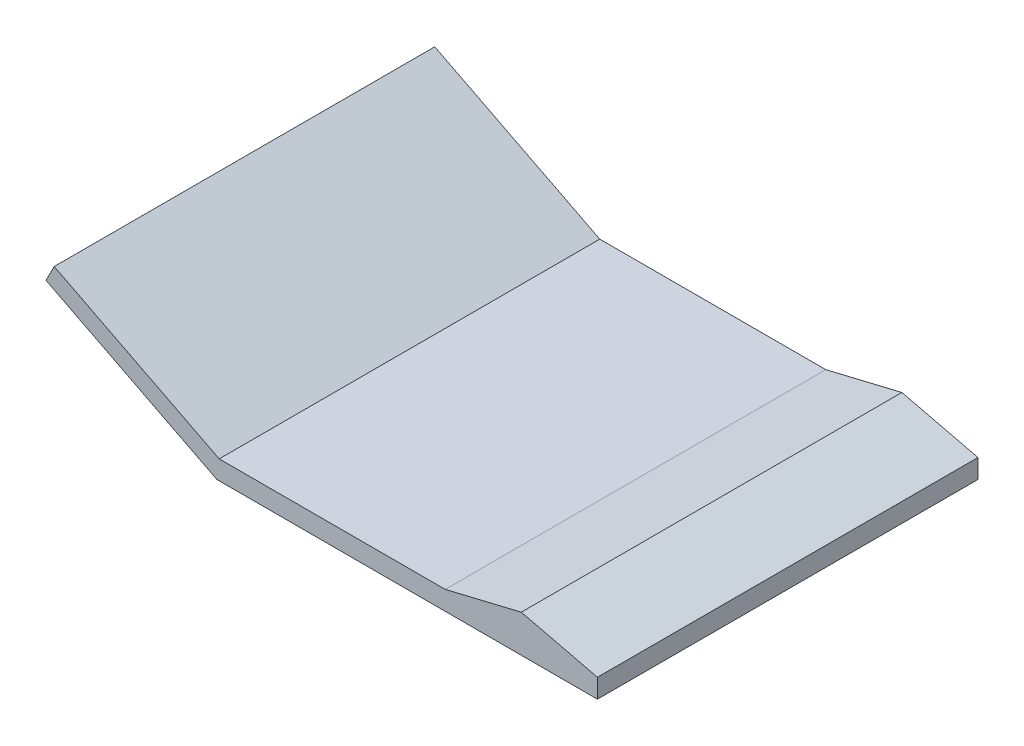
from build123d import *

# Parameters (mm, degrees)
RESSALTO_EXTRUS_O1_DEPTH = 400


with BuildPart() as part:
    # Esboço1 → Ressalto-extrusão1 (new body)
    with BuildSketch(Plane.XY):
        Polygon((8.601413754, 16.881224995), (0, 0), (400, 0), (400, 20), (240, 20), (2.480473166, 20), align=None)
        Polygon((-179.558563965, 91.489658015), (0, 0), (0, 20), (2.480473166, 20), (-170.957150212, 108.37088301), align=None)
        Polygon((0, 20), (0, 0), (8.601413754, 16.881224995), (2.480473166, 20), align=None)
        Polygon((240, 20), (400, 20), (320, 39.206300726), align=None)
    extrude(amount=RESSALTO_EXTRUS_O1_DEPTH)


solid = part.part
